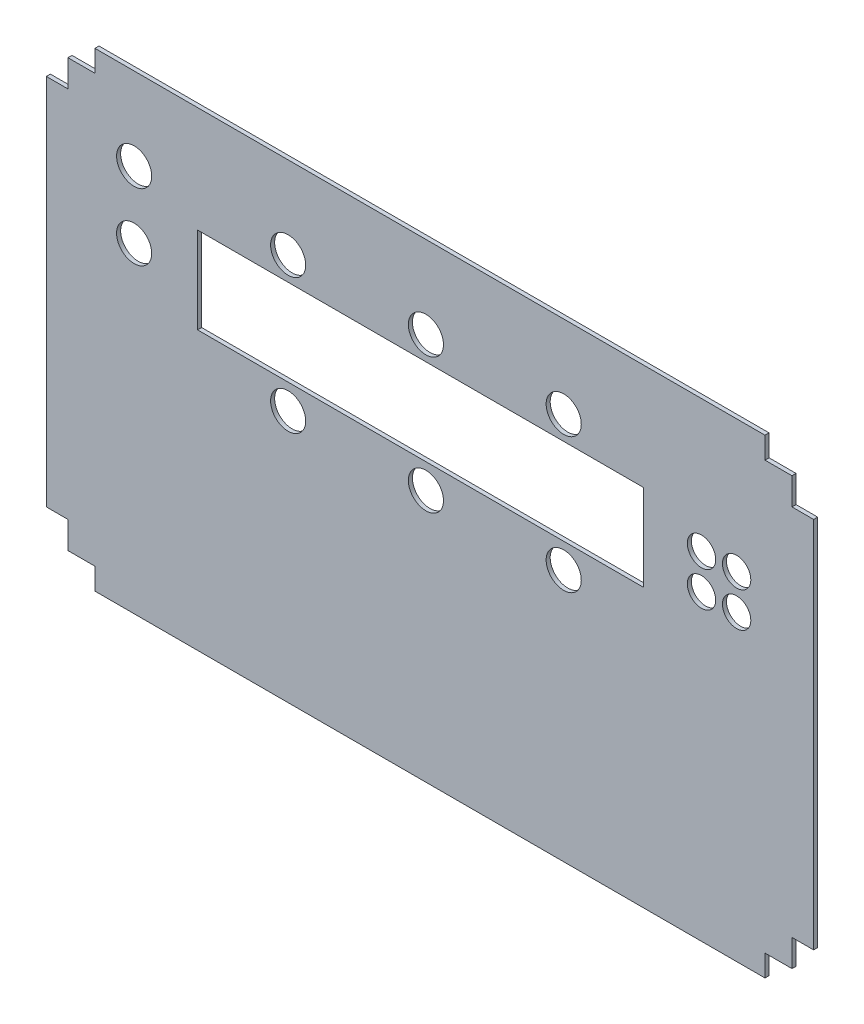
from build123d import *

# Parameters (mm, degrees)
MODEL_R                  = 6.5
MODEL_R_2                = 5.25
MODEL_W                  = 165
MODEL_H                  = 32
RESSALTO_EXTRUS_O1_DEPTH = 1.5


with BuildPart() as part:
    # Model → Ressalto-extrusão1 (new body)
    with BuildSketch(Plane.XY):
        Polygon((270.074227849, 25.427113901), (280.074227849, 25.427113901), (280.074227849, 35.427113901), (288.074227849, 35.427113901), (288.074227849, 173.427113901), (280.074227849, 173.427113901), (280.074227849, 183.427113901), (270.074227849, 183.427113901), (270.074227849, 191.427113901), (22.074227849, 191.427113901), (22.074227849, 183.427113901), (12.074227849, 183.427113901), (12.074227849, 173.427113901), (4.074227849, 173.427113901), (4.074227849, 35.427113901), (12.074227849, 35.427113901), (12.074227849, 25.427113901), (22.074227849, 25.427113901), (22.074227849, 17.427113901), (270.074227849, 17.427113901), align=None)
        with Locations((36.574227849, 160.927113901)):
            Circle(MODEL_R, mode=Mode.SUBTRACT)
        with Locations((36.574227849, 136.177113901)):
            Circle(MODEL_R, mode=Mode.SUBTRACT)
        with Locations((93.574227849, 110.927113901)):
            Circle(MODEL_R, mode=Mode.SUBTRACT)
        with Locations((144.574227849, 110.927113901)):
            Circle(MODEL_R, mode=Mode.SUBTRACT)
        with Locations((195.574227849, 110.927113901)):
            Circle(MODEL_R, mode=Mode.SUBTRACT)
        with Locations((195.574227849, 160.927113901)):
            Circle(MODEL_R, mode=Mode.SUBTRACT)
        with Locations((144.574227849, 160.927113901)):
            Circle(MODEL_R, mode=Mode.SUBTRACT)
        with Locations((93.574227849, 160.927113901)):
            Circle(MODEL_R, mode=Mode.SUBTRACT)
        with Locations((246.574227849, 142.427113901)):
            Circle(MODEL_R_2, mode=Mode.SUBTRACT)
        with Locations((259.574227849, 142.427113901)):
            Circle(MODEL_R_2, mode=Mode.SUBTRACT)
        with Locations((259.574227849, 129.427113901)):
            Circle(MODEL_R_2, mode=Mode.SUBTRACT)
        with Locations((246.574227849, 129.427113901)):
            Circle(MODEL_R_2, mode=Mode.SUBTRACT)
        with Locations((142.574227849, 136.177113901)):
            Rectangle(MODEL_W, MODEL_H, mode=Mode.SUBTRACT)
    extrude(amount=RESSALTO_EXTRUS_O1_DEPTH)


solid = part.part
